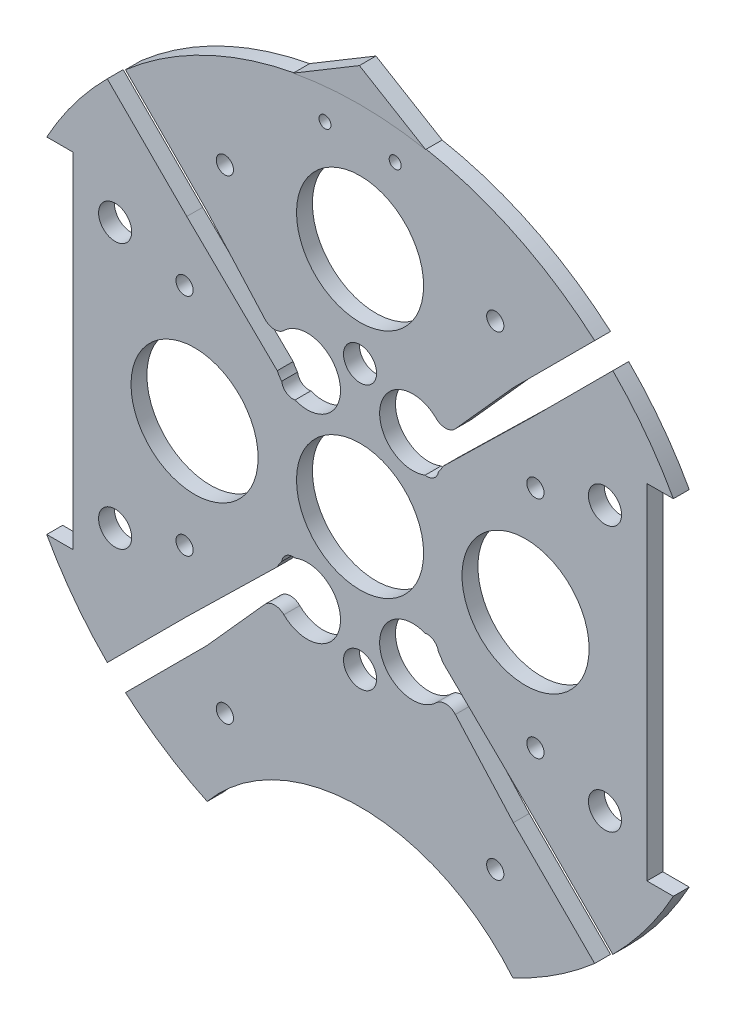
from build123d import *

# Parameters (mm, degrees)
BOSS_EXTRUDE2_DEPTH      = 3.048
SKETCH4_R                = 38.1
CUT_EXTRUDE3_DEPTH       = 4.048
BOSS_EXTRUDE3_DEPTH      = 3.175
SKETCH12_R               = 1.143
CUT_EXTRUDE9_DEPTH       = 4.175
SKETCH15_R               = 1.651
CUT_EXTRUDE12_DEPTH      = 75.692
SKETCH17_R               = 1.651
CUT_EXTRUDE14_DEPTH      = 97.79
SKETCH18_R               = 12.192
CUT_EXTRUDE15_DEPTH      = 35.56
SKETCH19_R               = 3.175
CUT_EXTRUDE16_DEPTH      = 103.378
CUT_EXTRUDE16_DEPTH_BACK = 48.768
SKETCH5_R                = 12.192
CUT_EXTRUDE6_DEPTH       = 4.175
FILLET1_R                = 2.54


with BuildPart() as part:
    # Sketch1 → Boss-Extrude2 (new body)
    with BuildSketch(Plane.XY):
        with BuildLine():
            Line((-60.107370596, 33.02), (-55.027370596, 33.02))
            Line((-55.027370596, 33.02), (-55.027370596, -33.02))
            Line((-55.027370596, -33.02), (-60.107370596, -33.02))
            ThreePointArc((-60.107370596, -33.02), (0, -68.58), (60.107370596, -33.02))
            Line((60.107370596, -33.02), (55.027370596, -33.02))
            Line((55.027370596, -33.02), (55.027370596, 33.02))
            Line((55.027370596, 33.02), (60.107370596, 33.02))
            ThreePointArc((60.107370596, 33.02), (0, 68.58), (-60.107370596, 33.02))
        make_face()
    extrude(amount=BOSS_EXTRUDE2_DEPTH)

    # Sketch4 → Cut-Extrude3 (cut, through all)
    with BuildSketch(Plane(origin=(0, 0, 0), x_dir=(-1, 0, 0), z_dir=(0, 0, -1))):
        with Locations((0, -86.312058398)):
            Circle(SKETCH4_R)
    extrude(amount=-CUT_EXTRUDE3_DEPTH, mode=Mode.SUBTRACT)

    # Sketch9 → Boss-Extrude3 (add)
    with BuildSketch(Plane(origin=(0, 0, 0), x_dir=(-1, 0, 0), z_dir=(0, 0, -1))):
        with BuildLine():
            Line((12.7, 67.39381574), (0, 75))
            Line((0, 75), (-12.7, 67.39381574))
            ThreePointArc((-12.7, 67.39381574), (0, 68.58), (12.7, 67.39381574))
        make_face()
    extrude(amount=-BOSS_EXTRUDE3_DEPTH)

    # Sketch12 → Cut-Extrude9 (cut, through all)
    with BuildSketch(Plane(origin=(0, 0, 0), x_dir=(-1, 0, 0), z_dir=(0, 0, -1))):
        with Locations((6.731, 62.23)):
            Circle(SKETCH12_R)
        with Locations((-6.731, 62.23)):
            Circle(SKETCH12_R)
    extrude(amount=-CUT_EXTRUDE9_DEPTH, mode=Mode.SUBTRACT)

    # Sketch15 → Cut-Extrude12 (cut)
    with BuildSketch(Plane(origin=(30.092005081, 4.08352975, -3.048), x_dir=(-1, 0, 0), z_dir=(0, 0, -1))):
        with Locations((63.757223581, 17.50647025)):
            Circle(SKETCH15_R)
        with Locations((63.757223581, -25.67352975)):
            Circle(SKETCH15_R)
        with Locations((-3.552776419, -25.67352975)):
            Circle(SKETCH15_R)
        with Locations((-3.552776419, 17.50647025)):
            Circle(SKETCH15_R)
    extrude(amount=-CUT_EXTRUDE12_DEPTH, mode=Mode.SUBTRACT)

    # Sketch17 → Cut-Extrude14 (cut)
    with BuildSketch(Plane(origin=(30.092005081, 4.08352975, -33.0835), x_dir=(-1, 0, 0), z_dir=(0, 0, -1))):
        with Locations((4.154396091, -49.728759131)):
            Circle(SKETCH17_R)
        with Locations((56.02961407, -49.728759131)):
            Circle(SKETCH17_R)
        with Locations((4.154396091, 41.38247025)):
            Circle(SKETCH17_R)
        with Locations((56.02961407, 41.38247025)):
            Circle(SKETCH17_R)
    extrude(amount=-CUT_EXTRUDE14_DEPTH, mode=Mode.SUBTRACT)

    # Sketch18 → Cut-Extrude15 (cut)
    with BuildSketch(Plane(origin=(0, 0, 0), x_dir=(-1, 0, 0), z_dir=(0, 0, -1))):
        with Locations((31.75, 0)):
            Circle(SKETCH18_R)
        with Locations((-31.75, 0)):
            Circle(SKETCH18_R)
    extrude(amount=-CUT_EXTRUDE15_DEPTH, mode=Mode.SUBTRACT)

    # Sketch19 → Cut-Extrude16 (cut, two sides)
    with BuildSketch(Plane(origin=(30.092005081, 4.08352975, 3.048), x_dir=(-1, 0, 0), z_dir=(0, 0, -1))) as cut_extrude16_sk:
        with Locations((-16.897994919, 21.31647025)):
            Circle(SKETCH19_R)
        with Locations((77.082005081, 21.31647025)):
            Circle(SKETCH19_R)
        with Locations((30.092005081, 21.31647025)):
            Circle(SKETCH19_R)
        with Locations((77.082005081, -29.48352975)):
            Circle(SKETCH19_R)
        with Locations((30.092005081, -29.48352975)):
            Circle(SKETCH19_R)
        with Locations((-16.897994919, -29.48352975)):
            Circle(SKETCH19_R)
    extrude(amount=CUT_EXTRUDE16_DEPTH, mode=Mode.SUBTRACT)
    extrude(cut_extrude16_sk.sketch, amount=-CUT_EXTRUDE16_DEPTH_BACK, mode=Mode.SUBTRACT)

    # Sketch5 → Cut-Extrude6 (cut, through all)
    with BuildSketch(Plane(origin=(0, 0, 0), x_dir=(-1, 0, 0), z_dir=(0, 0, -1))):
        with BuildLine():
            Line((45.125787008, -51.860979099), (48.493383054, -48.493383054))
            Line((48.493383054, -48.493383054), (33.244765274, -33.244765274))
            Line((33.244765274, -33.244765274), (15.887580142, -16.296407899))
            ThreePointArc((15.887580142, -16.296407899), (15.502857332, -15.608744759), (15.036339126, -14.973722712))
            ThreePointArc((15.036339126, -14.973722712), (14.151046139, -13.510927072), (12.484618985, -13.128127778))
            ThreePointArc((12.484618985, -13.128127778), (4.300657145, -21.652046912), (16.112224352, -21.303752637))
            Line((16.112224352, -21.303752637), (29.410338797, -36.145530887))
            Line((29.410338797, -36.145530887), (45.125787008, -51.860979099))
        make_face()
        with BuildLine():
            ThreePointArc((15.036339126, 14.973722712), (15.502857332, 15.608744759), (15.887580142, 16.296407899))
            Line((15.887580142, 16.296407899), (33.244765274, 33.244765274))
            Line((33.244765274, 33.244765274), (48.493383054, 48.493383054))
            Line((48.493383054, 48.493383054), (45.125787008, 51.860979099))
            Line((45.125787008, 51.860979099), (29.410338797, 36.145530887))
            Line((29.410338797, 36.145530887), (16.112224352, 21.303752637))
            ThreePointArc((16.112224352, 21.303752637), (4.300657145, 21.652046912), (12.484618985, 13.128127778))
            ThreePointArc((12.484618985, 13.128127778), (14.151046139, 13.510927072), (15.036339126, 14.973722712))
        make_face()
        with BuildLine():
            ThreePointArc((-12.484618985, 13.128127778), (-4.300657145, 21.652046912), (-16.112224352, 21.303752637))
            Line((-16.112224352, 21.303752637), (-29.410338797, 36.145530887))
            Line((-29.410338797, 36.145530887), (-45.125787008, 51.860979099))
            Line((-45.125787008, 51.860979099), (-48.493383054, 48.493383054))
            Line((-48.493383054, 48.493383054), (-33.244765274, 33.244765274))
            Line((-33.244765274, 33.244765274), (-15.887580142, 16.296407899))
            ThreePointArc((-15.887580142, 16.296407899), (-15.502857332, 15.608744759), (-15.036339126, 14.973722712))
            ThreePointArc((-15.036339126, 14.973722712), (-14.151046139, 13.510927072), (-12.484618985, 13.128127778))
        make_face()
        with BuildLine():
            Line((-45.125787008, -51.860979099), (-29.410338797, -36.145530887))
            Line((-29.410338797, -36.145530887), (-16.112224352, -21.303752637))
            ThreePointArc((-16.112224352, -21.303752637), (-4.300657145, -21.652046912), (-12.484618985, -13.128127778))
            ThreePointArc((-12.484618985, -13.128127778), (-14.151046139, -13.510927072), (-15.036339126, -14.973722712))
            ThreePointArc((-15.036339126, -14.973722712), (-15.502857332, -15.608744759), (-15.887580142, -16.296407899))
            Line((-15.887580142, -16.296407899), (-33.244765274, -33.244765274))
            Line((-33.244765274, -33.244765274), (-48.493383054, -48.493383054))
            Line((-48.493383054, -48.493383054), (-45.125787008, -51.860979099))
        make_face()
        Circle(SKETCH5_R)
        with Locations((0, 44.45)):
            Circle(SKETCH5_R)
    extrude(amount=-CUT_EXTRUDE6_DEPTH, mode=Mode.SUBTRACT)

    # Fillet1
    fillet1_edges = [part.edges().sort_by_distance(p)[0] for p in [
        (-16.112224352, -21.303752637, 1.524),
        (-16.112224352, 21.303752637, 1.524),
        (16.112224352, 21.303752637, 1.524),
        (16.112224352, -21.303752637, 1.524),
    ]]
    fillet(fillet1_edges, radius=FILLET1_R)


solid = part.part
